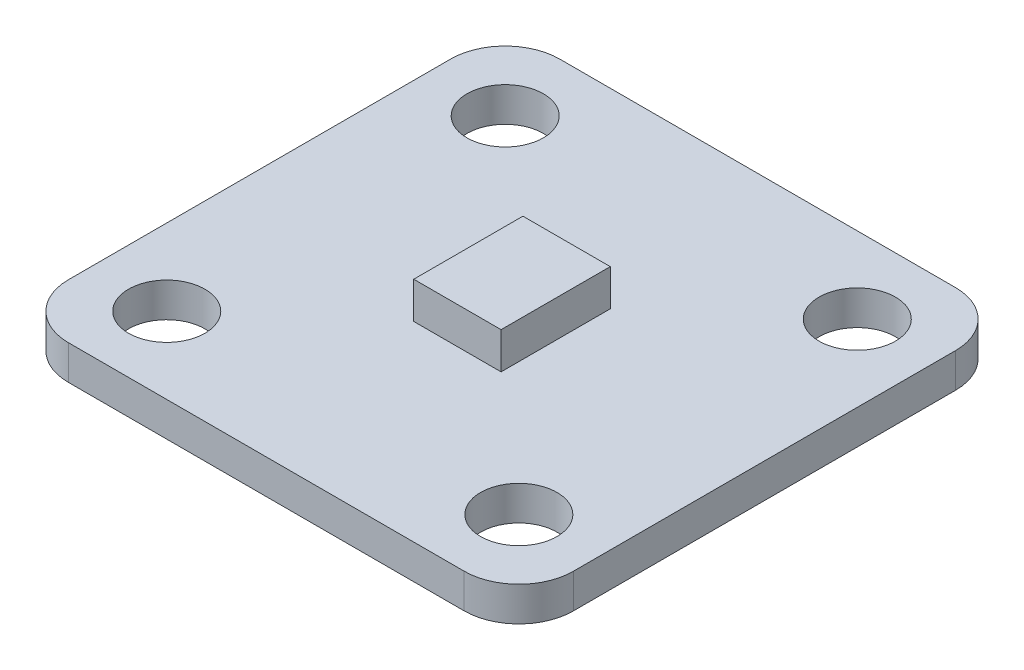
from build123d import *

# Parameters (mm, degrees)
SKETCH1_W           = 23.495
SKETCH1_H           = 22.86
BOSS_EXTRUDE1_DEPTH = 1.6002
SKETCH2_W           = 4.064
SKETCH2_H           = 5.08
BOSS_EXTRUDE2_DEPTH = 1.7018
FILLET1_R           = 2.54
SKETCH4_R           = 1.778
CUT_EXTRUDE1_DEPTH  = 2.6002


with BuildPart() as part:
    # Sketch1 → Boss-Extrude1 (new body)
    with BuildSketch(Plane(origin=(0, 0, 0), x_dir=(1, 0, 0), z_dir=(0, 1, 0))):
        Rectangle(SKETCH1_W, SKETCH1_H)
    extrude(amount=BOSS_EXTRUDE1_DEPTH)

    # Sketch2 → Boss-Extrude2 (add)
    with BuildSketch(Plane(origin=(0, 1.6002, 0), x_dir=(1, 0, 0), z_dir=(0, 1, 0))):
        Rectangle(SKETCH2_W, SKETCH2_H)
    extrude(amount=BOSS_EXTRUDE2_DEPTH)

    # Fillet1
    fillet1_edges = [part.edges().sort_by_distance(p)[0] for p in [
        (11.7475, 0.8001, 11.43),
        (-11.7475, 0.8001, 11.43),
        (-11.7475, 0.8001, -11.43),
        (11.7475, 0.8001, -11.43),
    ]]
    fillet(fillet1_edges, radius=FILLET1_R)

    # Sketch4 → Cut-Extrude1 (cut, through all)
    with BuildSketch(Plane(origin=(0, 1.6002, 0), x_dir=(1, 0, 0), z_dir=(0, 1, 0))):
        with Locations((-8.1915, -7.874)):
            Circle(SKETCH4_R)
        with Locations((-8.1915, 7.874)):
            Circle(SKETCH4_R)
        with Locations((8.1915, 7.874)):
            Circle(SKETCH4_R)
        with Locations((8.1915, -7.874)):
            Circle(SKETCH4_R)
    extrude(amount=-CUT_EXTRUDE1_DEPTH, mode=Mode.SUBTRACT)


solid = part.part
